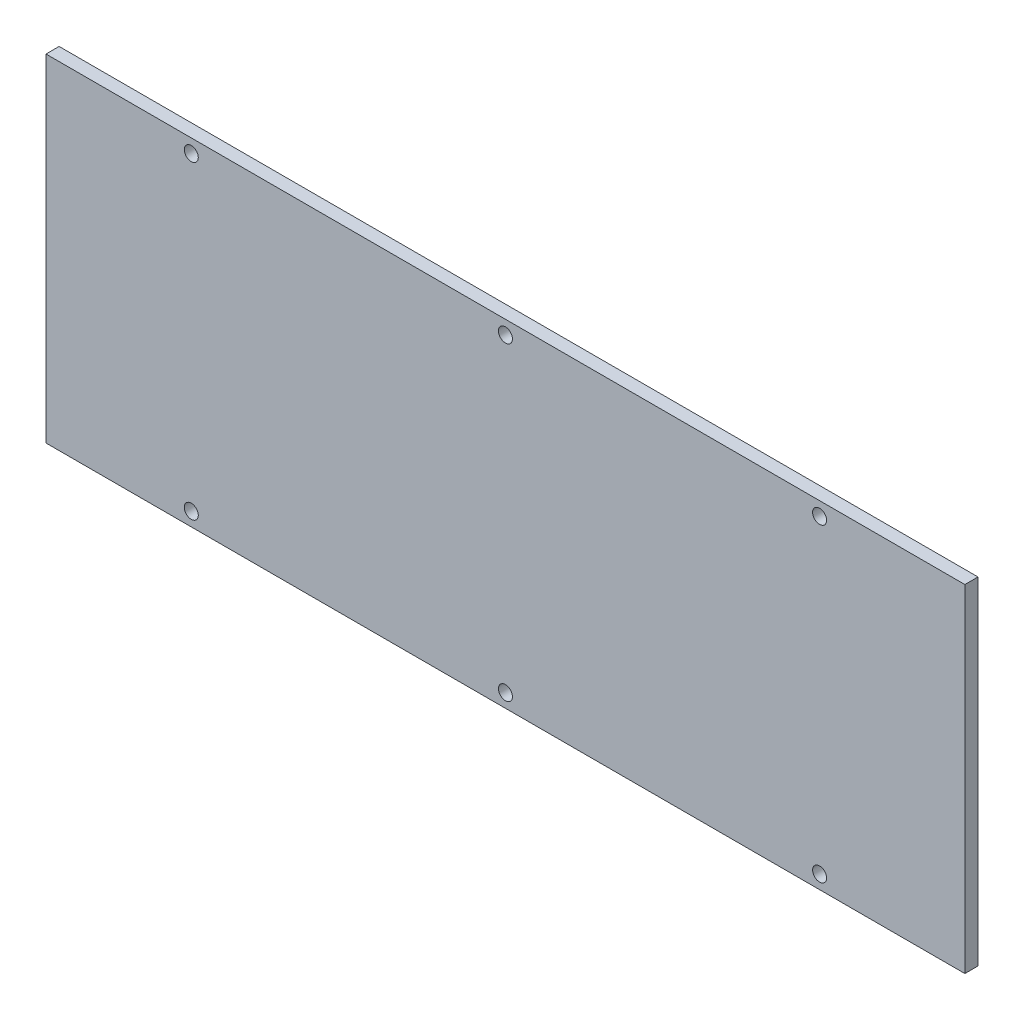
from build123d import *

# Parameters (mm, degrees)
CROQUIS1_W              = 210
CROQUIS1_H              = 77
CROQUIS1_R              = 1.6
SALIENTE_EXTRUIR1_DEPTH = 3


with BuildPart() as part:
    # Croquis1 → Saliente-Extruir1 (new body)
    with BuildSketch(Plane.XY):
        Rectangle(CROQUIS1_W, CROQUIS1_H)
        with Locations((0, 35.4)):
            Circle(CROQUIS1_R, mode=Mode.SUBTRACT)
        with Locations((-71.8, 35.4)):
            Circle(CROQUIS1_R, mode=Mode.SUBTRACT)
        with Locations((71.8, 35.4)):
            Circle(CROQUIS1_R, mode=Mode.SUBTRACT)
        with Locations((71.8, -35.4)):
            Circle(CROQUIS1_R, mode=Mode.SUBTRACT)
        with Locations((0, -35.4)):
            Circle(CROQUIS1_R, mode=Mode.SUBTRACT)
        with Locations((-71.8, -35.4)):
            Circle(CROQUIS1_R, mode=Mode.SUBTRACT)
    extrude(amount=SALIENTE_EXTRUIR1_DEPTH)


solid = part.part
